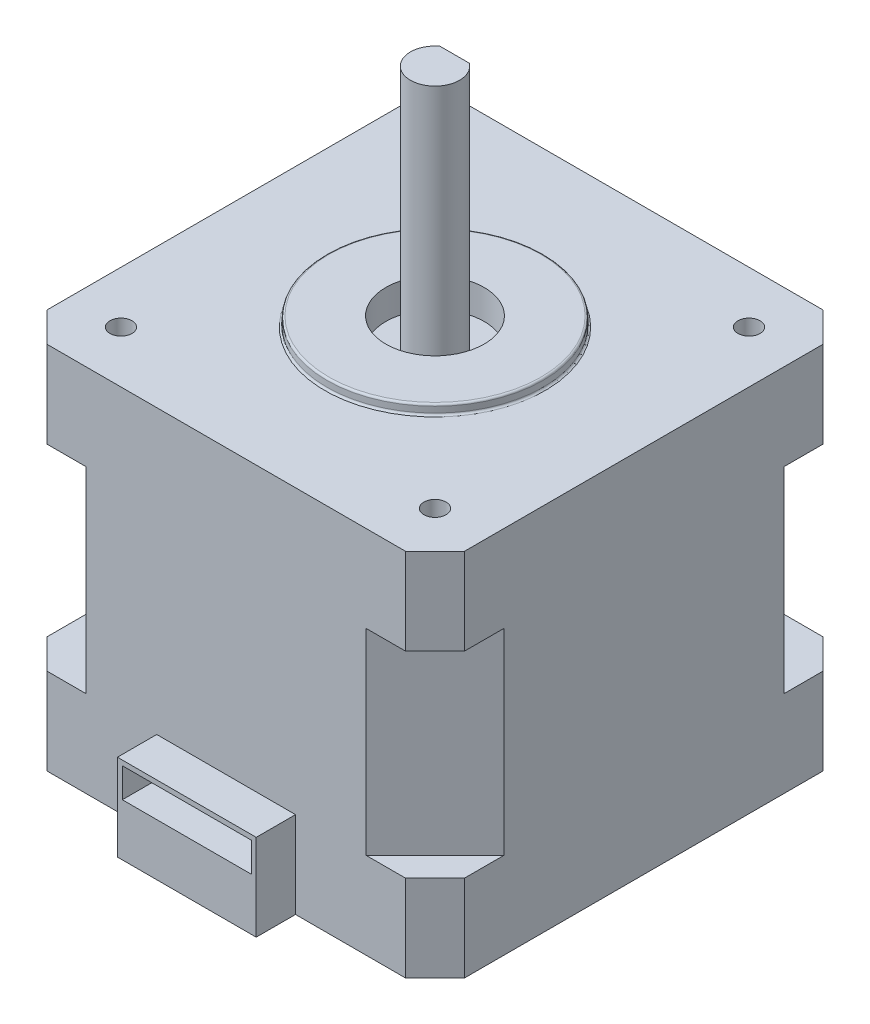
from build123d import *

# Parameters (mm, degrees)
BOSS_EXTRUDE1_DEPTH   = 18.8
SKETCH2_OUTSIDE_W     = 58.68
SKETCH2_OUTSIDE_H     = 58.68
CUT_EXTRUDE1_DEPTH    = 10
SKETCH3_W             = 14.12047277
SKETCH3_H             = 8.8
BOSS_EXTRUDE2_DEPTH   = 4
SKETCH4_W             = 13.12047277
SKETCH4_H             = 3
CUT_EXTRUDE2_DEPTH    = 4
SKETCH5_R             = 4.5
CUT_EXTRUDE3_DEPTH    = 3
SKETCH6_R             = 11
BOSS_EXTRUDE3_DEPTH   = 1
FILLET1_R             = 0.2
SKETCH7_R             = 5
CUT_EXTRUDE4_DEPTH    = 3
BOSS_EXTRUDE4_DEPTH   = 25
ESBO_O1_R             = 1.125
CORTE_EXTRUS_O1_DEPTH = 5.5


with BuildPart() as part:
    # Sketch1 → Boss-Extrude1 (new body, symmetric)
    with BuildSketch(Plane(origin=(0, 0, 0), x_dir=(1, 0, 0), z_dir=(0, 1, 0))):
        Polygon((-21.25, 18.25), (-18.25, 21.25), (18.25, 21.25), (21.25, 18.25), (21.25, -18.25), (18.25, -21.25), (-18.25, -21.25), (-21.25, -18.25), align=None)
    extrude(amount=BOSS_EXTRUDE1_DEPTH, both=True)

    # Sketch2 outside → Cut-Extrude1 (cut, symmetric)
    with BuildSketch(Plane(origin=(0, 0, 0), x_dir=(1, 0, 0), z_dir=(0, 1, 0))):
        Rectangle(SKETCH2_OUTSIDE_W, SKETCH2_OUTSIDE_H)
        Polygon((-21.25, 14.25), (-21.25, -14.25), (-14.25, -21.25), (14.25, -21.25), (21.25, -14.25), (21.25, 14.25), (14.25, 21.25), (-14.25, 21.25), align=None, mode=Mode.SUBTRACT)
    extrude(amount=CUT_EXTRUDE1_DEPTH, both=True, mode=Mode.SUBTRACT)

    # Sketch3 → Boss-Extrude2 (add)
    with BuildSketch(Plane.XY.offset(21.25)):
        with Locations((0, -14.4)):
            Rectangle(SKETCH3_W, SKETCH3_H)
    extrude(amount=BOSS_EXTRUDE2_DEPTH)

    # Sketch4 → Cut-Extrude2 (cut)
    with BuildSketch(Plane.XY.offset(25.25)):
        with Locations((0, -12)):
            Rectangle(SKETCH4_W, SKETCH4_H)
    extrude(amount=-CUT_EXTRUDE2_DEPTH, mode=Mode.SUBTRACT)

    # Sketch5 → Cut-Extrude3 (cut)
    with BuildSketch(Plane.XZ.offset(18.8)):
        Circle(SKETCH5_R)
    extrude(amount=-CUT_EXTRUDE3_DEPTH, mode=Mode.SUBTRACT)

    # Sketch6 → Boss-Extrude3 (add)
    with BuildSketch(Plane(origin=(0, 18.8, 0), x_dir=(1, 0, 0), z_dir=(0, 1, 0))):
        Circle(SKETCH6_R)
    extrude(amount=BOSS_EXTRUDE3_DEPTH)

    # Fillet1
    fillet1_edges = [part.edges().sort_by_distance(p)[0] for p in [
        (-11, 18.8, 0),
        (-11, 19.8, 0),
    ]]
    fillet(fillet1_edges, radius=FILLET1_R)

    # Sketch7 → Cut-Extrude4 (cut)
    with BuildSketch(Plane(origin=(0, 19.8, 0), x_dir=(1, 0, 0), z_dir=(0, 1, 0))):
        Circle(SKETCH7_R)
    extrude(amount=-CUT_EXTRUDE4_DEPTH, mode=Mode.SUBTRACT)

    # Esboço1 → Corte-extrusão1 (cut)
    with BuildSketch(Plane(origin=(0, 18.8, 0), x_dir=(1, 0, 0), z_dir=(0, 1, 0))):
        with Locations((-15.975, 15.975)):
            Circle(ESBO_O1_R)
        with Locations((15.975, 15.975)):
            Circle(ESBO_O1_R)
        with Locations((15.975, -15.975)):
            Circle(ESBO_O1_R)
        with Locations((-15.975, -15.975)):
            Circle(ESBO_O1_R)
    extrude(amount=-CORTE_EXTRUS_O1_DEPTH, mode=Mode.SUBTRACT)


with BuildPart() as body_2:
    # Sketch8 → Boss-Extrude4 (new body)
    with BuildSketch(Plane(origin=(0, 16.8, 0), x_dir=(1, 0, 0), z_dir=(0, 1, 0))):
        with BuildLine():
            Line((-1.5, 2), (1.5, 2))
            ThreePointArc((1.5, 2), (0, -2.5), (-1.5, 2))
        make_face()
    extrude(amount=BOSS_EXTRUDE4_DEPTH)


solid = Compound([part.part, body_2.part])
